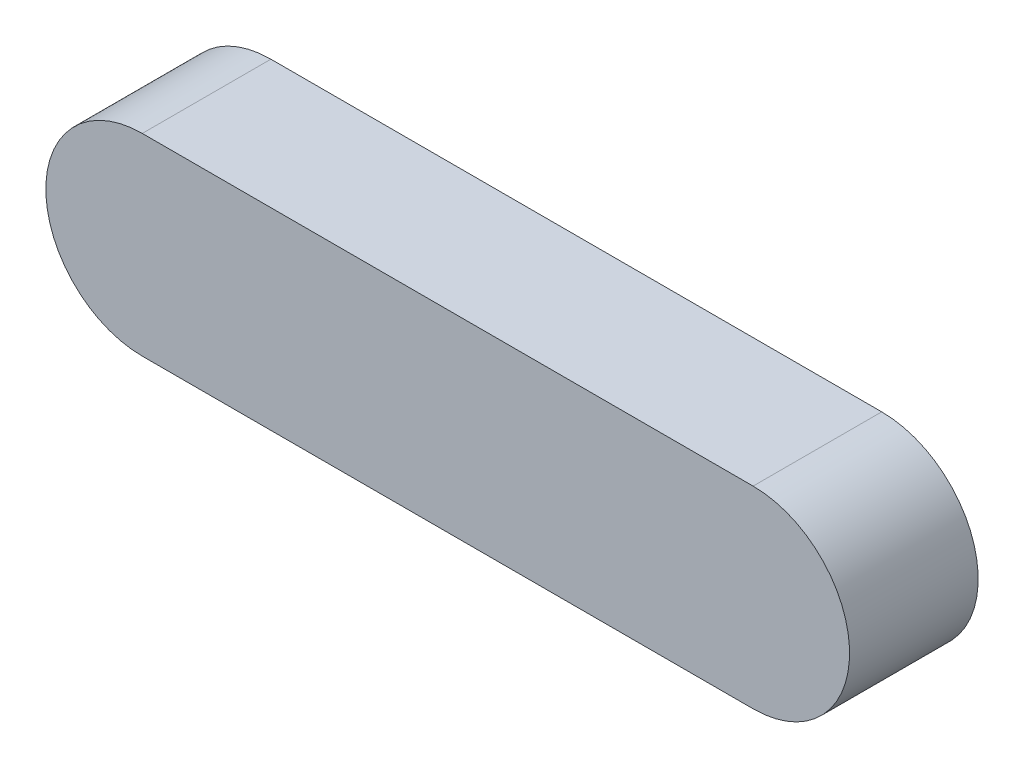
from build123d import *

# Parameters (mm, degrees)
BOSS_EXTRUDE1_DEPTH = 8


with BuildPart() as part:
    # Sketch1 → Boss-Extrude1 (new body)
    with BuildSketch(Plane.XY):
        with BuildLine():
            Line((-19, 6), (0, 6))
            Line((0, 6), (0, -6))
            Line((0, -6), (-19, -6))
            ThreePointArc((-19, -6), (-25, 0), (-19, 6))
        make_face()
    boss_extrude1 = extrude(amount=BOSS_EXTRUDE1_DEPTH)

    # Mirror1: Boss-Extrude1 across plane
    add(boss_extrude1.mirror(Plane(origin=(0, 6, 8), x_dir=(0, 0, 1), z_dir=(-1, 0, 0))))


solid = part.part
